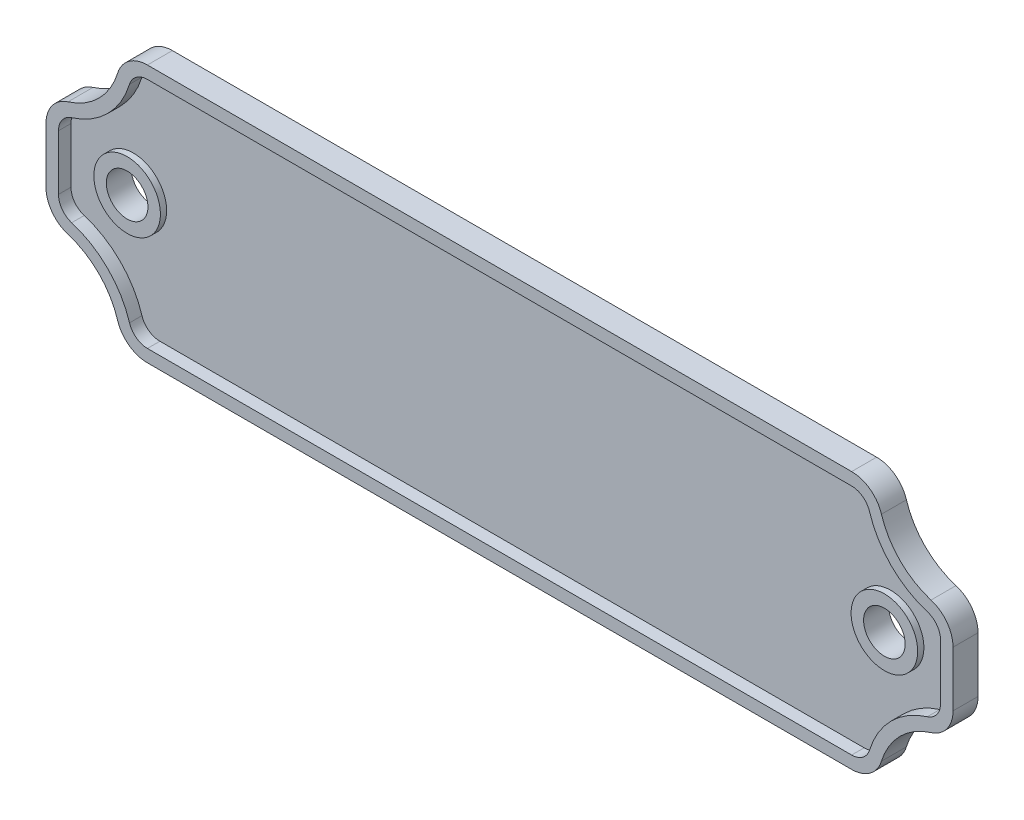
from build123d import *

# Parameters (mm, degrees)
SKETCH1_R                = 4
BOSS_EXTRUDE1_DEPTH      = 1.5
BOSS_EXTRUDE3_DEPTH      = 2.25
BOSS_EXTRUDE3_DEPTH_BACK = 0.75
SKETCH1_4_R              = 4
SKETCH1_4_R_2            = 2.5
BOSS_EXTRUDE4_DEPTH      = 3


with BuildPart() as part:
    # Sketch1 → Boss-Extrude1 (new body)
    with BuildSketch(Plane.XY):
        with BuildLine():
            Line((-42.313942393, 14), (42.313942393, 14))
            ThreePointArc((42.313942393, 14), (43.650641576, 13.55989925), (44.464423147, 12.411764706))
            ThreePointArc((44.464423147, 12.411764706), (47.075378798, 8.075378798), (51.411764706, 5.464423147))
            ThreePointArc((51.411764706, 5.464423147), (52.55989925, 4.650641576), (53, 3.313942393))
            Line((53, 3.313942393), (53, -3.313942393))
            ThreePointArc((53, -3.313942393), (52.55989925, -4.650641576), (51.411764706, -5.464423147))
            ThreePointArc((51.411764706, -5.464423147), (47.075378798, -8.075378798), (44.464423147, -12.411764706))
            ThreePointArc((44.464423147, -12.411764706), (43.650641576, -13.55989925), (42.313942393, -14))
            Line((42.313942393, -14), (-42.313942393, -14))
            ThreePointArc((-42.313942393, -14), (-43.650641576, -13.55989925), (-44.464423147, -12.411764706))
            ThreePointArc((-44.464423147, -12.411764706), (-47.075378798, -8.075378798), (-51.411764706, -5.464423147))
            ThreePointArc((-51.411764706, -5.464423147), (-52.55989925, -4.650641576), (-53, -3.313942393))
            Line((-53, -3.313942393), (-53, 3.313942393))
            ThreePointArc((-53, 3.313942393), (-52.55989925, 4.650641576), (-51.411764706, 5.464423147))
            ThreePointArc((-51.411764706, 5.464423147), (-47.075378798, 8.075378798), (-44.464423147, 12.411764706))
            ThreePointArc((-44.464423147, 12.411764706), (-43.650641576, 13.55989925), (-42.313942393, 14))
        make_face()
        with Locations((-45.5, 0)):
            Circle(SKETCH1_R, mode=Mode.SUBTRACT)
        with Locations((45.5, 0)):
            Circle(SKETCH1_R, mode=Mode.SUBTRACT)
    extrude(amount=BOSS_EXTRUDE1_DEPTH)

    # Sketch1_4 → Boss-Extrude3 (add, two sides: drawn at the far end of the back side and taken through both)
    # profile 1 of 2: a face of its own
    with BuildSketch(Plane.XY.offset(-BOSS_EXTRUDE3_DEPTH_BACK)):
        with Locations((-45.5, 0)):
            Circle(SKETCH1_4_R)
        with Locations((-45.5, 0)):
            Circle(SKETCH1_4_R_2, mode=Mode.SUBTRACT)
    # profile 2 of 2: a face of its own
    with BuildSketch(Plane.XY.offset(-BOSS_EXTRUDE3_DEPTH_BACK)):
        with Locations((45.5, 0)):
            Circle(SKETCH1_4_R)
        with Locations((45.5, 0)):
            Circle(SKETCH1_4_R_2, mode=Mode.SUBTRACT)
    extrude(amount=BOSS_EXTRUDE3_DEPTH + BOSS_EXTRUDE3_DEPTH_BACK)

    # Sketch1_5 → Boss-Extrude4 (add)
    with BuildSketch(Plane.XY):
        with BuildLine():
            Line((42.313942393, 15.5), (-42.313942393, 15.5))
            ThreePointArc((-42.313942393, 15.5), (-44.541774365, 14.76649875), (-45.898076983, 12.852941176))
            ThreePointArc((-45.898076983, 12.852941176), (-48.136038969, 9.136038969), (-51.852941176, 6.898076983))
            ThreePointArc((-51.852941176, 6.898076983), (-53.76649875, 5.541774365), (-54.5, 3.313942393))
            Line((-54.5, 3.313942393), (-54.5, -3.313942393))
            ThreePointArc((-54.5, -3.313942393), (-53.76649875, -5.541774365), (-51.852941176, -6.898076983))
            ThreePointArc((-51.852941176, -6.898076983), (-48.136038969, -9.136038969), (-45.898076983, -12.852941176))
            ThreePointArc((-45.898076983, -12.852941176), (-44.541774365, -14.76649875), (-42.313942393, -15.5))
            Line((-42.313942393, -15.5), (42.313942393, -15.5))
            ThreePointArc((42.313942393, -15.5), (44.541774365, -14.76649875), (45.898076983, -12.852941176))
            ThreePointArc((45.898076983, -12.852941176), (48.136038969, -9.136038969), (51.852941176, -6.898076983))
            ThreePointArc((51.852941176, -6.898076983), (53.76649875, -5.541774365), (54.5, -3.313942393))
            Line((54.5, -3.313942393), (54.5, 3.313942393))
            ThreePointArc((54.5, 3.313942393), (53.76649875, 5.541774365), (51.852941176, 6.898076983))
            ThreePointArc((51.852941176, 6.898076983), (48.136038969, 9.136038969), (45.898076983, 12.852941176))
            ThreePointArc((45.898076983, 12.852941176), (44.541774365, 14.76649875), (42.313942393, 15.5))
        make_face()
        with BuildLine():
            ThreePointArc((-44.464423147, 12.411764706), (-43.650641576, 13.55989925), (-42.313942393, 14))
            Line((-42.313942393, 14), (42.313942393, 14))
            ThreePointArc((42.313942393, 14), (43.650641576, 13.55989925), (44.464423147, 12.411764706))
            ThreePointArc((44.464423147, 12.411764706), (47.075378798, 8.075378798), (51.411764706, 5.464423147))
            ThreePointArc((51.411764706, 5.464423147), (52.55989925, 4.650641576), (53, 3.313942393))
            Line((53, 3.313942393), (53, -3.313942393))
            ThreePointArc((53, -3.313942393), (52.55989925, -4.650641576), (51.411764706, -5.464423147))
            ThreePointArc((51.411764706, -5.464423147), (47.075378798, -8.075378798), (44.464423147, -12.411764706))
            ThreePointArc((44.464423147, -12.411764706), (43.650641576, -13.55989925), (42.313942393, -14))
            Line((42.313942393, -14), (-42.313942393, -14))
            ThreePointArc((-42.313942393, -14), (-43.650641576, -13.55989925), (-44.464423147, -12.411764706))
            ThreePointArc((-44.464423147, -12.411764706), (-47.075378798, -8.075378798), (-51.411764706, -5.464423147))
            ThreePointArc((-51.411764706, -5.464423147), (-52.55989925, -4.650641576), (-53, -3.313942393))
            Line((-53, -3.313942393), (-53, 3.313942393))
            ThreePointArc((-53, 3.313942393), (-52.55989925, 4.650641576), (-51.411764706, 5.464423147))
            ThreePointArc((-51.411764706, 5.464423147), (-47.075378798, 8.075378798), (-44.464423147, 12.411764706))
        make_face(mode=Mode.SUBTRACT)
    extrude(amount=BOSS_EXTRUDE4_DEPTH)


solid = part.part
